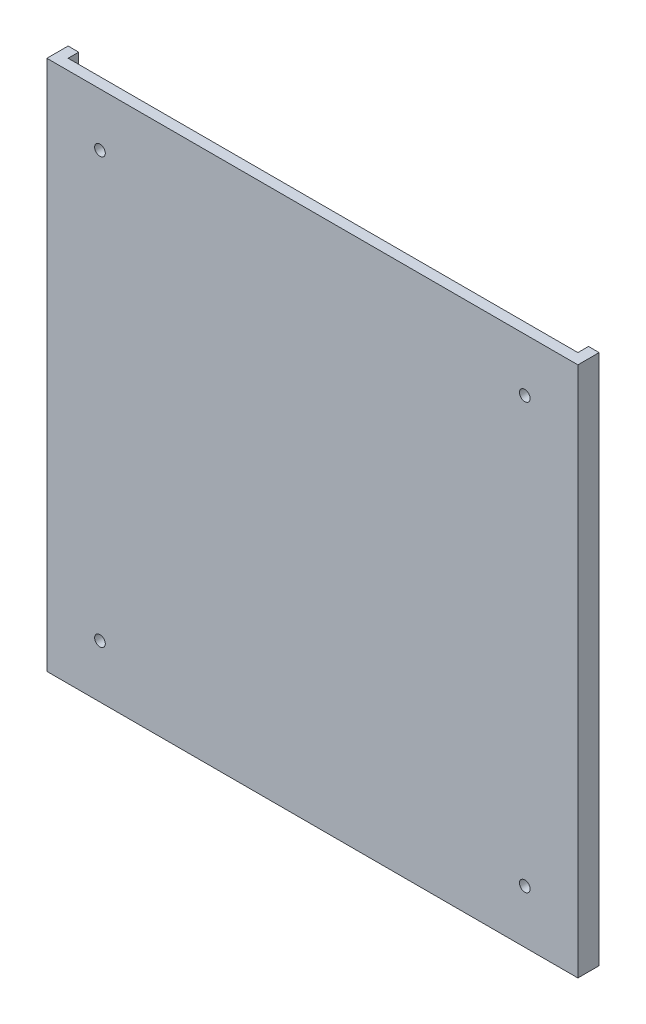
from build123d import *

# Parameters (mm, degrees)
SKETCH1_W           = 500
SKETCH1_H           = 500
BOSS_EXTRUDE1_DEPTH = 20
SKETCH2_W           = 480
SKETCH2_H           = 10
CUT_EXTRUDE1_DEPTH  = 500
SKETCH3_R           = 5
CUT_EXTRUDE2_DEPTH  = 10


with BuildPart() as part:
    # Sketch1 → Boss-Extrude1 (new body)
    with BuildSketch(Plane.XY):
        Rectangle(SKETCH1_W, SKETCH1_H)
    extrude(amount=BOSS_EXTRUDE1_DEPTH)

    # Sketch2 → Cut-Extrude1 (cut)
    with BuildSketch(Plane(origin=(0, 250, 0), x_dir=(1, 0, 0), z_dir=(0, 1, 0))):
        with Locations((0, -5)):
            Rectangle(SKETCH2_W, SKETCH2_H)
    extrude(amount=-CUT_EXTRUDE1_DEPTH, mode=Mode.SUBTRACT)

    # Sketch3 → Cut-Extrude2 (cut)
    with BuildSketch(Plane.XY.offset(20)):
        with Locations((-200, 200)):
            Circle(SKETCH3_R)
        with Locations((200, 200)):
            Circle(SKETCH3_R)
        with Locations((-200, -200)):
            Circle(SKETCH3_R)
        with Locations((200, -200)):
            Circle(SKETCH3_R)
    extrude(amount=-CUT_EXTRUDE2_DEPTH, mode=Mode.SUBTRACT)


solid = part.part
